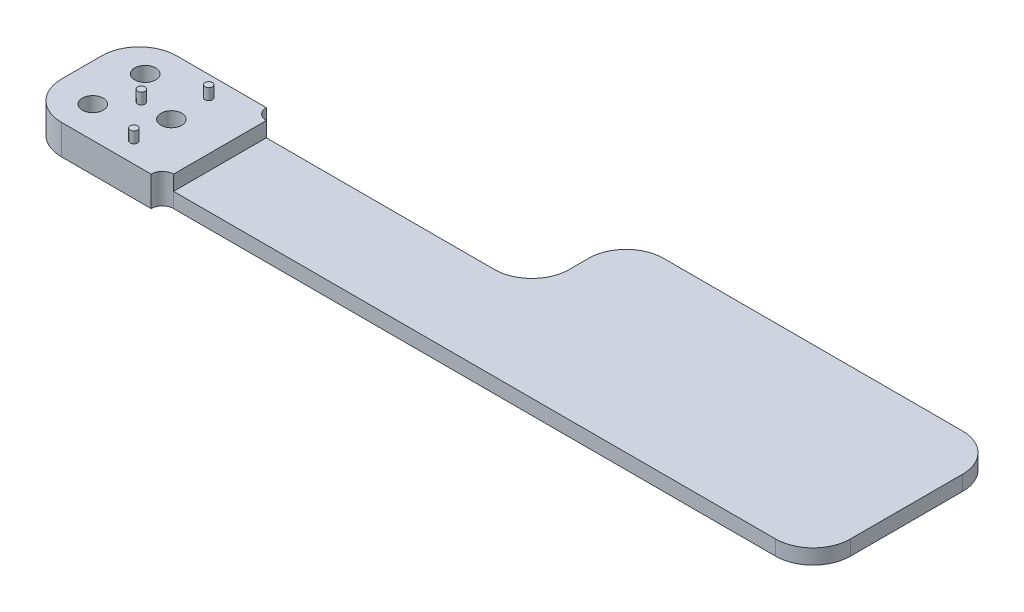
from build123d import *

# Parameters (mm, degrees)
SKETCH_1_W          = 17
SKETCH_1_H          = 12.4
EXTRUDE_1_DEPTH     = 4
SKETCH_2_R          = 1.4
CUT_EXTRUDE_1_DEPTH = 3
SKETCH_3_W          = 12.4
SKETCH_3_H          = 2
EXTRUDE_2_DEPTH     = 37
SKETCH_4_W          = 17
SKETCH_4_H          = 1.5
EXTRUDE_3_DEPTH     = 4
FILLET_1_R          = 5
SKETCH_5_R          = 0.5
EXTRUDE_4_DEPTH     = 1.5
EXTRUDE_5_DEPTH     = 2
SKETCH_7_W          = 50
SKETCH_7_H          = 25
EXTRUDE_6_DEPTH     = 2
FILLET_2_R          = 5
FILLET_3_R          = 5
EXTRUDE_7_DEPTH     = 2


with BuildPart() as part:
    # 草图1 → 凸台-拉伸1 (new body)
    with BuildSketch(Plane(origin=(0, 0, 0), x_dir=(1, 0, 0), z_dir=(0, 1, 0))):
        with Locations((8.5, 6.2)):
            Rectangle(SKETCH_1_W, SKETCH_1_H)
    extrude(amount=EXTRUDE_1_DEPTH)

    # 草图2 → 切除-拉伸1 (cut)
    with BuildSketch(Plane(origin=(0, 4, 0), x_dir=(1, 0, 0), z_dir=(0, 1, 0))):
        with Locations((12, 6.2)):
            Circle(SKETCH_2_R)
        with Locations((5, 9.7)):
            Circle(SKETCH_2_R)
        with Locations((5, 2.7)):
            Circle(SKETCH_2_R)
    extrude(amount=-CUT_EXTRUDE_1_DEPTH, mode=Mode.SUBTRACT)

    # 草图3 → 凸台-拉伸2 (add)
    with BuildSketch(Plane(origin=(17, 0, 0), x_dir=(0, 0, -1), z_dir=(1, 0, 0))):
        with Locations((6.2, 1)):
            Rectangle(SKETCH_3_W, SKETCH_3_H)
    extrude(amount=EXTRUDE_2_DEPTH)

    # 草图4 → 凸台-拉伸3 (add)
    with BuildSketch(Plane(origin=(0, 4, 0), x_dir=(1, 0, 0), z_dir=(0, 1, 0))):
        with Locations((8.5, 13.15)):
            Rectangle(SKETCH_4_W, SKETCH_4_H)
        with Locations((8.5, -0.75)):
            Rectangle(SKETCH_4_W, SKETCH_4_H)
    extrude(amount=-EXTRUDE_3_DEPTH)

    # 圆角1
    fillet_1_edges = [part.edges().sort_by_distance(p)[0] for p in [
        (0, 2, -13.9),
        (0, 2, 1.5),
    ]]
    fillet(fillet_1_edges, radius=FILLET_1_R)

    # 草图5 → 凸台-拉伸4 (add)
    with BuildSketch(Plane(origin=(0, 4, 0), x_dir=(1, 0, 0), z_dir=(0, 1, 0))):
        with Locations((8, 6.2)):
            Circle(SKETCH_5_R)
        with Locations((12, 11.2)):
            Circle(SKETCH_5_R)
        with Locations((12, 1.2)):
            Circle(SKETCH_5_R)
    extrude(amount=EXTRUDE_4_DEPTH)

    # 草图6 → 凸台-拉伸5 (add)
    with BuildSketch(Plane(origin=(0, 2, 0), x_dir=(1, 0, 0), z_dir=(0, 1, 0))):
        with BuildLine():
            Line((17, 13.9), (17, 12.4))
            Line((17, 12.4), (18.5, 12.4))
            ThreePointArc((18.5, 12.4), (17.439339828, 12.839339828), (17, 13.9))
        make_face()
        with BuildLine():
            Line((17, -1.5), (17, 0))
            Line((17, 0), (18.5, 0))
            ThreePointArc((18.5, 0), (17.439339828, -0.439339828), (17, -1.5))
        make_face()
    extrude(amount=-EXTRUDE_5_DEPTH)

    # 草图7 → 凸台-拉伸6 (add)
    with BuildSketch(Plane.XZ):
        with Locations((79, -12.5)):
            Rectangle(SKETCH_7_W, SKETCH_7_H)
    extrude(amount=-EXTRUDE_6_DEPTH)

    # 圆角2
    fillet_2_edges = [part.edges().sort_by_distance(p)[0] for p in [
        (54, 1, -25),
        (54, 1, -12.4),
    ]]
    fillet(fillet_2_edges, radius=FILLET_2_R)

    # 圆角3
    fillet_3_edges = [part.edges().sort_by_distance(p)[0] for p in [
        (104, 1, 0),
        (104, 1, -25),
    ]]
    fillet(fillet_3_edges, radius=FILLET_3_R)

    # 草图8 → 凸台-拉伸7 (add)
    with BuildSketch(Plane(origin=(0, 2, 0), x_dir=(1, 0, 0), z_dir=(0, 1, 0))):
        with BuildLine():
            Line((18.5, 0), (18.5, 12.4))
            ThreePointArc((18.5, 12.4), (17.439339828, 12.839339828), (17, 13.9))
            Line((17, 13.9), (17, -1.5))
            ThreePointArc((17, -1.5), (17.439339828, -0.439339828), (18.5, 0))
        make_face()
    extrude(amount=EXTRUDE_7_DEPTH)


solid = part.part
